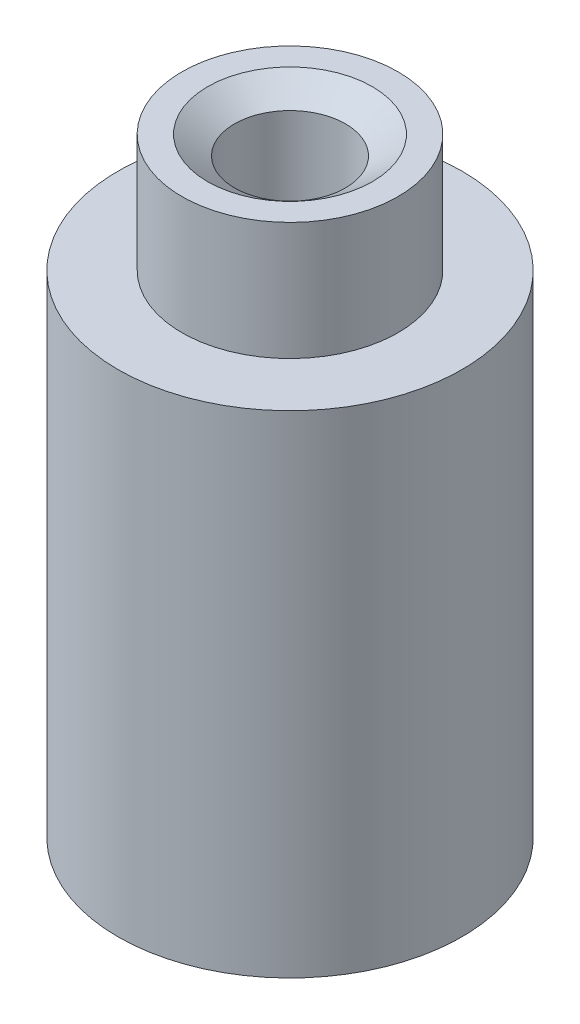
from build123d import *


with BuildPart() as part:
    # Эскиз1 → Повернуть1 (revolve)
    with BuildSketch(Plane(origin=(0, 0, 0), x_dir=(0, 0, -1), z_dir=(1, 0, 0))):
        Polygon((0, 0), (0, 12.4), (2.2, 12.4), (2.2, 10), (3.5, 10), (3.5, 0), align=None)
    revolve(axis=Axis((0, 0, 0), (0, 1, 0)))

    # Эскиз2 → Отверстие обработанное метчиком #4-401 (revolve, cut)
    with BuildSketch(Plane(origin=(0, 0, 0), x_dir=(0, 0, -1), z_dir=(1, 0, 0))):
        Polygon((0, 0), (0, 12.4), (1.6764, 12.4), (1.1303, 12.017616663), (1.1303, 0.382383337), (1.6764, 0), align=None)
    revolve(axis=Axis((0, -6.35, 0), (0, 1, 0)), mode=Mode.SUBTRACT)


solid = part.part
